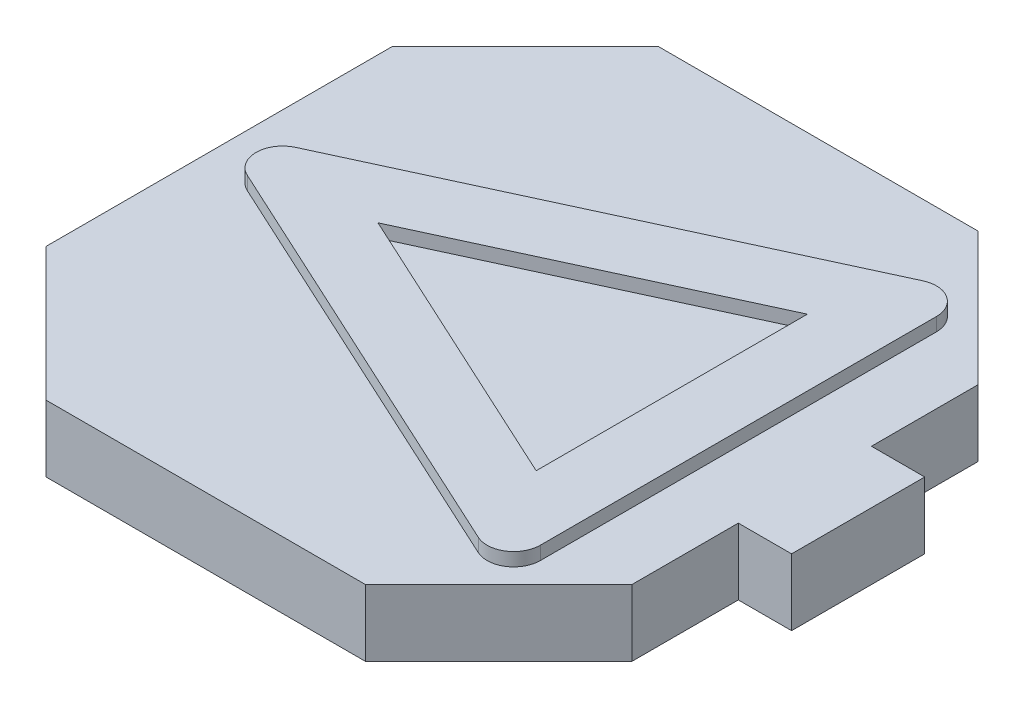
from build123d import *

# Parameters (mm, degrees)
BOSS_EXTRU_1_DEPTH      = 5
BOSS_EXTRU_2_DEPTH      = 1
ESQUISSE3_W             = 5.2
ESQUISSE3_H             = 5.2
ESQUISSE3_W_2           = 5
ESQUISSE3_H_2           = 5
ENL_V_MAT_EXTRU_1_DEPTH = 4.8
CONG_4_R                = 2


with BuildPart() as part:
    # Esquisse1 → Boss.-Extru.1 (new body)
    with BuildSketch(Plane(origin=(0, 0, 0), x_dir=(1, 0, 0), z_dir=(0, 1, 0))):
        Polygon((22, 13), (12.003020456, 23), (-12.003020456, 23), (-22, 13), (-22, -13), (-12.003020456, -23), (12.003020456, -23), (22, -13), (22, -5), (26, -5), (26, 5), (22, 5), align=None)
    extrude(amount=BOSS_EXTRU_1_DEPTH)

    # Esquisse2 → Boss.-Extru.2 (add)
    with BuildSketch(Plane(origin=(0, 5, 0), x_dir=(1, 0, 0), z_dir=(0, 1, 0))):
        Polygon((17.001510228, -18), (17.001510228, 18), (-22, 0), align=None)
        Polygon((-10.06810155, 0), (12.001510228, -10.185580242), (12.001510228, 10.185580242), align=None, mode=Mode.SUBTRACT)
    extrude(amount=BOSS_EXTRU_2_DEPTH)

    # Esquisse3 → Enlèv. mat.-Extru.1 (cut)
    with BuildSketch(Plane.XZ):
        with Locations((-13.4, 14.4)):
            Rectangle(ESQUISSE3_W, ESQUISSE3_H)
        with Locations((-13.4, -14.4)):
            Rectangle(ESQUISSE3_W, ESQUISSE3_H)
        with Locations((13.4, -14.4)):
            Rectangle(ESQUISSE3_W, ESQUISSE3_H)
        with Locations((13.4, 14.4)):
            Rectangle(ESQUISSE3_W, ESQUISSE3_H)
        Rectangle(ESQUISSE3_W_2, ESQUISSE3_H_2)
    extrude(amount=-ENL_V_MAT_EXTRU_1_DEPTH, mode=Mode.SUBTRACT)

    # Congé4
    cong_4_edges = [part.edges().sort_by_distance(p)[0] for p in [
        (-22, 5.5, 0),
        (17.001510228, 5.5, 18),
        (17.001510228, 5.5, -18),
    ]]
    fillet(cong_4_edges, radius=CONG_4_R)


solid = part.part
